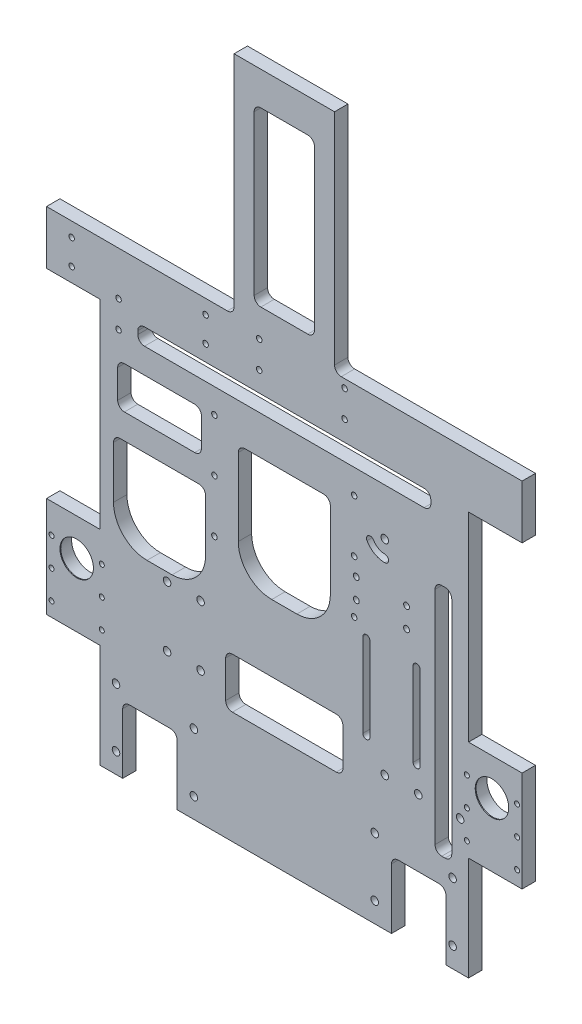
from build123d import *

# Parameters (mm, degrees)
ESQUISSE1_W                   = 220
ESQUISSE1_H                   = 285
BOSS_EXTRU_1_DEPTH            = 8
ESQUISSE2_R                   = 2
ENL_V_MAT_EXTRU_1_DEPTH       = 8
ESQUISSE3_W                   = 55
ESQUISSE3_H                   = 70
ESQUISSE3_H_2                 = 55
ESQUISSE3_W_2                 = 10
ESQUISSE3_H_3                 = 140
ENL_V_MAT_EXTRU_2_DEPTH       = 1
ENL_V_MAT_EXTRU_2_DEPTH_BACK  = 9
ESQUISSE5_W                   = 175
ESQUISSE5_H                   = 10
ENL_V_MAT_EXTRU_3_DEPTH       = 1
ENL_V_MAT_EXTRU_3_DEPTH_BACK  = 9
ESQUISSE6_R                   = 2.25
ESQUISSE6_R_2                 = 1.75
ENL_V_MAT_EXTRU_4_DEPTH       = 1
ENL_V_MAT_EXTRU_4_DEPTH_BACK  = 9
ESQUISSE7_R                   = 1.65
ENL_V_MAT_EXTRU_5_DEPTH       = 1
ENL_V_MAT_EXTRU_5_DEPTH_BACK  = 9
ESQUISSE8_W                   = 32.5
ESQUISSE8_H                   = 40
ENL_V_MAT_EXTRU_6_DEPTH       = 1
ENL_V_MAT_EXTRU_6_DEPTH_BACK  = 9
CONG_1_R                      = 20
ENL_V_MAT_EXTRU_7_DEPTH       = 1
ENL_V_MAT_EXTRU_7_DEPTH_BACK  = 9
ESQUISSE10_R                  = 2.25
ENL_V_MAT_EXTRU_8_DEPTH       = 1
ENL_V_MAT_EXTRU_8_DEPTH_BACK  = 9
ESQUISSE11_W                  = 70
ESQUISSE11_H                  = 30
ENL_V_MAT_EXTRU_9_DEPTH       = 1
ENL_V_MAT_EXTRU_9_DEPTH_BACK  = 9
ESQUISSE12_R                  = 2.25
ENL_V_MAT_EXTRU_10_DEPTH      = 1
ENL_V_MAT_EXTRU_10_DEPTH_BACK = 9
ESQUISSE13_R                  = 2.25
ENL_V_MAT_EXTRU_11_DEPTH      = 1
ENL_V_MAT_EXTRU_11_DEPTH_BACK = 9
ESQUISSE14_W                  = 80
ESQUISSE14_H                  = 12
ENL_V_MAT_EXTRU_12_DEPTH      = 1
ENL_V_MAT_EXTRU_12_DEPTH_BACK = 9
ESQUISSE15_W                  = 60
ESQUISSE15_H                  = 123
BOSS_EXTRU_2_DEPTH            = 8
ESQUISSE16_W                  = 36
ESQUISSE16_H                  = 103
ENL_V_MAT_EXTRU_13_DEPTH      = 1
ENL_V_MAT_EXTRU_13_DEPTH_BACK = 9
ESQUISSE17_W                  = 32
ESQUISSE17_H                  = 32
ESQUISSE17_H_2                = 60
BOSS_EXTRU_3_DEPTH            = 8
ESQUISSE18_W                  = 50
ESQUISSE18_H                  = 25
ENL_V_MAT_EXTRU_14_DEPTH      = 1
ENL_V_MAT_EXTRU_14_DEPTH_BACK = 9
CONG_2_R                      = 4
ESQUISSE19_R                  = 1.65
ENL_V_MAT_EXTRU_15_DEPTH      = 1
ENL_V_MAT_EXTRU_15_DEPTH_BACK = 9
ESQUISSE20_R                  = 11.025
ENL_V_MAT_EXTRU_16_DEPTH      = 7.5
ESQUISSE21_R                  = 10
ENL_V_MAT_EXTRU_17_DEPTH      = 8.5
ENL_V_MAT_EXTRU_17_DEPTH_BACK = 1.5
ESQUISSE22_R                  = 1.5
ENL_V_MAT_EXTRU_18_DEPTH      = 1
ENL_V_MAT_EXTRU_18_DEPTH_BACK = 9


with BuildPart() as part:
    # Esquisse1 → Boss.-Extru.1 (new body)
    with BuildSketch(Plane.XY):
        with Locations((110, 142.5)):
            Rectangle(ESQUISSE1_W, ESQUISSE1_H)
    extrude(amount=BOSS_EXTRU_1_DEPTH)

    # Esquisse2 → Enlèv. mat.-Extru.1 (cut)
    with BuildSketch(Plane.XZ):
        with Locations((110, 4)):
            Circle(ESQUISSE2_R)
        with Locations((213, 4)):
            Circle(ESQUISSE2_R)
        with Locations((7, 4)):
            Circle(ESQUISSE2_R)
    extrude(amount=-ENL_V_MAT_EXTRU_1_DEPTH, mode=Mode.SUBTRACT)

    # Esquisse3 → Enlèv. mat.-Extru.2 (cut, two sides)
    with BuildSketch(Plane.XY.offset(8)) as enl_v_mat_extru_2_sk:
        with Locations((110, 172)):
            Rectangle(ESQUISSE3_W, ESQUISSE3_H)
        with Locations((35.5, 147.5)):
            Rectangle(ESQUISSE3_W, ESQUISSE3_H_2)
        with Locations((205, 125)):
            Rectangle(ESQUISSE3_W_2, ESQUISSE3_H_3)
    extrude(amount=ENL_V_MAT_EXTRU_2_DEPTH, mode=Mode.SUBTRACT)
    extrude(enl_v_mat_extru_2_sk.sketch, amount=-ENL_V_MAT_EXTRU_2_DEPTH_BACK, mode=Mode.SUBTRACT)

    # Esquisse5 → Enlèv. mat.-Extru.3 (cut, two sides)
    with BuildSketch(Plane.XY.offset(8)) as enl_v_mat_extru_3_sk:
        with Locations((110, 235)):
            Rectangle(ESQUISSE5_W, ESQUISSE5_H)
    extrude(amount=ENL_V_MAT_EXTRU_3_DEPTH, mode=Mode.SUBTRACT)
    extrude(enl_v_mat_extru_3_sk.sketch, amount=-ENL_V_MAT_EXTRU_3_DEPTH_BACK, mode=Mode.SUBTRACT)

    # Esquisse6 → Enlèv. mat.-Extru.4 (cut, two sides)
    with BuildSketch(Plane.XY.offset(8)) as enl_v_mat_extru_4_sk:
        with Locations((190, 80)):
            Circle(ESQUISSE6_R)
        with Locations((170, 80)):
            Circle(ESQUISSE6_R)
        with Locations((215, 80)):
            Circle(ESQUISSE6_R)
        with Locations((153, 174)):
            Circle(ESQUISSE6_R_2)
        with Locations((183, 174)):
            Circle(ESQUISSE6_R_2)
        with Locations((183, 162)):
            Circle(ESQUISSE6_R_2)
        with Locations((153, 162)):
            Circle(ESQUISSE6_R_2)
    extrude(amount=ENL_V_MAT_EXTRU_4_DEPTH, mode=Mode.SUBTRACT)
    extrude(enl_v_mat_extru_4_sk.sketch, amount=-ENL_V_MAT_EXTRU_4_DEPTH_BACK, mode=Mode.SUBTRACT)

    # Esquisse7 → Enlèv. mat.-Extru.5 (cut, two sides)
    with BuildSketch(Plane.XY.offset(8)) as enl_v_mat_extru_5_sk:
        with Locations((68.285, 215.4)):
            Circle(ESQUISSE7_R)
        with Locations((68.285, 184)):
            Circle(ESQUISSE7_R)
        with Locations((68.285, 152.6)):
            Circle(ESQUISSE7_R)
        with Locations((151.715, 152.6)):
            Circle(ESQUISSE7_R)
        with Locations((151.715, 184)):
            Circle(ESQUISSE7_R)
        with Locations((151.715, 215.4)):
            Circle(ESQUISSE7_R)
        with Locations((95, 268)):
            Circle(ESQUISSE7_R)
        with Locations((146, 268)):
            Circle(ESQUISSE7_R)
        with Locations((146, 252)):
            Circle(ESQUISSE7_R)
        with Locations((95, 252)):
            Circle(ESQUISSE7_R)
    extrude(amount=ENL_V_MAT_EXTRU_5_DEPTH, mode=Mode.SUBTRACT)
    extrude(enl_v_mat_extru_5_sk.sketch, amount=-ENL_V_MAT_EXTRU_5_DEPTH_BACK, mode=Mode.SUBTRACT)

    # Esquisse8 → Enlèv. mat.-Extru.6 (cut, two sides)
    with BuildSketch(Plane.XY.offset(8)) as enl_v_mat_extru_6_sk:
        with Locations((190.25, 20)):
            Rectangle(ESQUISSE8_W, ESQUISSE8_H)
        with Locations((29.75, 20)):
            Rectangle(ESQUISSE8_W, ESQUISSE8_H)
    extrude(amount=ENL_V_MAT_EXTRU_6_DEPTH, mode=Mode.SUBTRACT)
    extrude(enl_v_mat_extru_6_sk.sketch, amount=-ENL_V_MAT_EXTRU_6_DEPTH_BACK, mode=Mode.SUBTRACT)

    # Congé1
    cong_1_edges = [part.edges().sort_by_distance(p)[0] for p in [
        (8, 120, 4),
        (63, 120, 4),
        (137.5, 137, 4),
        (82.5, 137, 4),
    ]]
    fillet(cong_1_edges, radius=CONG_1_R)

    # Esquisse9 → Enlèv. mat.-Extru.7 (cut, two sides)
    with BuildSketch(Plane.XY.offset(8)) as enl_v_mat_extru_7_sk:
        with BuildLine():
            Line((191.1, 145), (191.1, 95))
            ThreePointArc((191.1, 95), (189, 92.9), (186.9, 95))
            Line((186.9, 95), (186.9, 145))
            ThreePointArc((186.9, 145), (189, 147.1), (191.1, 145))
        make_face()
        with BuildLine():
            Line((156.9, 95), (156.9, 145))
            ThreePointArc((156.9, 145), (159, 147.1), (161.1, 145))
            Line((161.1, 145), (161.1, 95))
            ThreePointArc((161.1, 95), (159, 92.9), (156.9, 95))
        make_face()
    extrude(amount=ENL_V_MAT_EXTRU_7_DEPTH, mode=Mode.SUBTRACT)
    extrude(enl_v_mat_extru_7_sk.sketch, amount=-ENL_V_MAT_EXTRU_7_DEPTH_BACK, mode=Mode.SUBTRACT)

    # Esquisse10 → Enlèv. mat.-Extru.8 (cut, two sides)
    with BuildSketch(Plane.XY.offset(8)) as enl_v_mat_extru_8_sk:
        with Locations((9.5, 12)):
            Circle(ESQUISSE10_R)
        with Locations((9.5, 47)):
            Circle(ESQUISSE10_R)
        with Locations((210.5, 47)):
            Circle(ESQUISSE10_R)
        with Locations((210.5, 12)):
            Circle(ESQUISSE10_R)
        with Locations((56, 47)):
            Circle(ESQUISSE10_R)
        with Locations((56, 12)):
            Circle(ESQUISSE10_R)
        with Locations((164, 12)):
            Circle(ESQUISSE10_R)
        with Locations((164, 47)):
            Circle(ESQUISSE10_R)
    extrude(amount=ENL_V_MAT_EXTRU_8_DEPTH, mode=Mode.SUBTRACT)
    extrude(enl_v_mat_extru_8_sk.sketch, amount=-ENL_V_MAT_EXTRU_8_DEPTH_BACK, mode=Mode.SUBTRACT)

    # Esquisse11 → Enlèv. mat.-Extru.9 (cut, two sides)
    with BuildSketch(Plane.XY.offset(8)) as enl_v_mat_extru_9_sk:
        with Locations((110, 82)):
            Rectangle(ESQUISSE11_W, ESQUISSE11_H)
    extrude(amount=ENL_V_MAT_EXTRU_9_DEPTH, mode=Mode.SUBTRACT)
    extrude(enl_v_mat_extru_9_sk.sketch, amount=-ENL_V_MAT_EXTRU_9_DEPTH_BACK, mode=Mode.SUBTRACT)

    # Esquisse12 → Enlèv. mat.-Extru.10 (cut, two sides)
    with BuildSketch(Plane.XY.offset(8)) as enl_v_mat_extru_10_sk:
        with Locations((170, 202)):
            Circle(ESQUISSE12_R)
        with BuildLine():
            ThreePointArc((159.391188804, 195.875), (163.875, 191.391188804), (170, 189.75))
            ThreePointArc((170, 189.75), (172.25, 192), (170, 194.25))
            ThreePointArc((170, 194.25), (166.125, 195.288303121), (163.288303121, 198.125))
            ThreePointArc((163.288303121, 198.125), (160.214745962, 198.948557159), (159.391188804, 195.875))
        make_face()
    extrude(amount=ENL_V_MAT_EXTRU_10_DEPTH, mode=Mode.SUBTRACT)
    extrude(enl_v_mat_extru_10_sk.sketch, amount=-ENL_V_MAT_EXTRU_10_DEPTH_BACK, mode=Mode.SUBTRACT)

    # Esquisse13 → Enlèv. mat.-Extru.11 (cut, two sides)
    with BuildSketch(Plane.XY.offset(8)) as enl_v_mat_extru_11_sk:
        with Locations((40, 115)):
            Circle(ESQUISSE13_R)
        with Locations((60, 115)):
            Circle(ESQUISSE13_R)
        with Locations((60, 79)):
            Circle(ESQUISSE13_R)
        with Locations((40, 79)):
            Circle(ESQUISSE13_R)
    extrude(amount=ENL_V_MAT_EXTRU_11_DEPTH, mode=Mode.SUBTRACT)
    extrude(enl_v_mat_extru_11_sk.sketch, amount=-ENL_V_MAT_EXTRU_11_DEPTH_BACK, mode=Mode.SUBTRACT)

    # Esquisse14 → Enlèv. mat.-Extru.12 (cut, two sides)
    with BuildSketch(Plane.XY.offset(8)) as enl_v_mat_extru_12_sk:
        with Locations((40, 279)):
            Rectangle(ESQUISSE14_W, ESQUISSE14_H)
        with Locations((180, 279)):
            Rectangle(ESQUISSE14_W, ESQUISSE14_H)
    extrude(amount=ENL_V_MAT_EXTRU_12_DEPTH, mode=Mode.SUBTRACT)
    extrude(enl_v_mat_extru_12_sk.sketch, amount=-ENL_V_MAT_EXTRU_12_DEPTH_BACK, mode=Mode.SUBTRACT)

    # Esquisse15 → Boss.-Extru.2 (add)
    with BuildSketch(Plane.XY.offset(8)):
        with Locations((110, 346.5)):
            Rectangle(ESQUISSE15_W, ESQUISSE15_H)
    extrude(amount=-BOSS_EXTRU_2_DEPTH)

    # Esquisse16 → Enlèv. mat.-Extru.13 (cut, two sides)
    with BuildSketch(Plane.XY.offset(8)) as enl_v_mat_extru_13_sk:
        with Locations((110, 336.5)):
            Rectangle(ESQUISSE16_W, ESQUISSE16_H)
    extrude(amount=ENL_V_MAT_EXTRU_13_DEPTH, mode=Mode.SUBTRACT)
    extrude(enl_v_mat_extru_13_sk.sketch, amount=-ENL_V_MAT_EXTRU_13_DEPTH_BACK, mode=Mode.SUBTRACT)

    # Esquisse17 → Boss.-Extru.3 (add)
    with BuildSketch(Plane.XY.offset(8)):
        with Locations((236, 257)):
            Rectangle(ESQUISSE17_W, ESQUISSE17_H)
        with Locations((-16, 257)):
            Rectangle(ESQUISSE17_W, ESQUISSE17_H)
        with Locations((-16, 92)):
            Rectangle(ESQUISSE17_W, ESQUISSE17_H_2)
        with Locations((236, 92)):
            Rectangle(ESQUISSE17_W, ESQUISSE17_H_2)
    extrude(amount=-BOSS_EXTRU_3_DEPTH)

    # Esquisse18 → Enlèv. mat.-Extru.14 (cut, two sides)
    with BuildSketch(Plane.XY.offset(8)) as enl_v_mat_extru_14_sk:
        with Locations((35.5, 202.5)):
            Rectangle(ESQUISSE18_W, ESQUISSE18_H)
    extrude(amount=ENL_V_MAT_EXTRU_14_DEPTH, mode=Mode.SUBTRACT)
    extrude(enl_v_mat_extru_14_sk.sketch, amount=-ENL_V_MAT_EXTRU_14_DEPTH_BACK, mode=Mode.SUBTRACT)

    # Congé2
    cong_2_edges = [part.edges().sort_by_distance(p)[0] for p in [
        (13.5, 40, 4),
        (46, 40, 4),
        (174, 40, 4),
        (206.5, 40, 4),
        (8, 175, 4),
        (63, 175, 4),
        (75, 67, 4),
        (75, 97, 4),
        (145, 97, 4),
        (145, 67, 4),
        (80, 273, 4),
        (140, 273, 4),
        (92, 285, 4),
        (92, 388, 4),
        (128, 388, 4),
        (128, 285, 4),
        (137.5, 207, 4),
        (82.5, 207, 4),
        (10.5, 190, 4),
        (10.5, 215, 4),
        (60.5, 215, 4),
        (60.5, 190, 4),
        (200, 55, 4),
        (200, 195, 4),
        (210, 195, 4),
        (210, 55, 4),
        (22.5, 230, 4),
        (22.5, 240, 4),
        (197.5, 240, 4),
        (197.5, 230, 4),
    ]]
    fillet(cong_2_edges, radius=CONG_2_R)

    # Esquisse19 → Enlèv. mat.-Extru.15 (cut, two sides)
    with BuildSketch(Plane.XY.offset(8)) as enl_v_mat_extru_15_sk:
        with Locations((-17, 264.5)):
            Circle(ESQUISSE19_R)
        with Locations((-17, 249.5)):
            Circle(ESQUISSE19_R)
        with Locations((63, 249.5)):
            Circle(ESQUISSE19_R)
        with Locations((63, 264.5)):
            Circle(ESQUISSE19_R)
        with Locations((11, 246.8)):
            Circle(ESQUISSE19_R)
        with Locations((11, 230.8)):
            Circle(ESQUISSE19_R)
    extrude(amount=ENL_V_MAT_EXTRU_15_DEPTH, mode=Mode.SUBTRACT)
    extrude(enl_v_mat_extru_15_sk.sketch, amount=-ENL_V_MAT_EXTRU_15_DEPTH_BACK, mode=Mode.SUBTRACT)

    # Esquisse20 → Enlèv. mat.-Extru.16 (cut)
    with BuildSketch(Plane.XY):
        with Locations((-14, 100)):
            Circle(ESQUISSE20_R)
        with Locations((234, 100)):
            Circle(ESQUISSE20_R)
    extrude(amount=ENL_V_MAT_EXTRU_16_DEPTH, mode=Mode.SUBTRACT)

    # Esquisse21 → Enlèv. mat.-Extru.17 (cut, two sides)
    with BuildSketch(Plane(origin=(0, 0, 7.5), x_dir=(-1, 0, 0), z_dir=(0, 0, -1))) as enl_v_mat_extru_17_sk:
        with Locations((14, 100)):
            Circle(ESQUISSE21_R)
        with Locations((-234, 100)):
            Circle(ESQUISSE21_R)
    extrude(amount=ENL_V_MAT_EXTRU_17_DEPTH, mode=Mode.SUBTRACT)
    extrude(enl_v_mat_extru_17_sk.sketch, amount=-ENL_V_MAT_EXTRU_17_DEPTH_BACK, mode=Mode.SUBTRACT)

    # Esquisse22 → Enlèv. mat.-Extru.18 (cut, two sides)
    with BuildSketch(Plane.XY.offset(8)) as enl_v_mat_extru_18_sk:
        with Locations((-29, 70.5)):
            Circle(ESQUISSE22_R)
        with Locations((-29, 87.5)):
            Circle(ESQUISSE22_R)
        with Locations((-29, 104.5)):
            Circle(ESQUISSE22_R)
        with Locations((1, 104.5)):
            Circle(ESQUISSE22_R)
        with Locations((1, 87.5)):
            Circle(ESQUISSE22_R)
        with Locations((1, 70.5)):
            Circle(ESQUISSE22_R)
        with Locations((219, 70.5)):
            Circle(ESQUISSE22_R)
        with Locations((219, 87.5)):
            Circle(ESQUISSE22_R)
        with Locations((219, 104.5)):
            Circle(ESQUISSE22_R)
        with Locations((249, 104.5)):
            Circle(ESQUISSE22_R)
        with Locations((249, 87.5)):
            Circle(ESQUISSE22_R)
        with Locations((249, 70.5)):
            Circle(ESQUISSE22_R)
    extrude(amount=ENL_V_MAT_EXTRU_18_DEPTH, mode=Mode.SUBTRACT)
    extrude(enl_v_mat_extru_18_sk.sketch, amount=-ENL_V_MAT_EXTRU_18_DEPTH_BACK, mode=Mode.SUBTRACT)


solid = part.part
